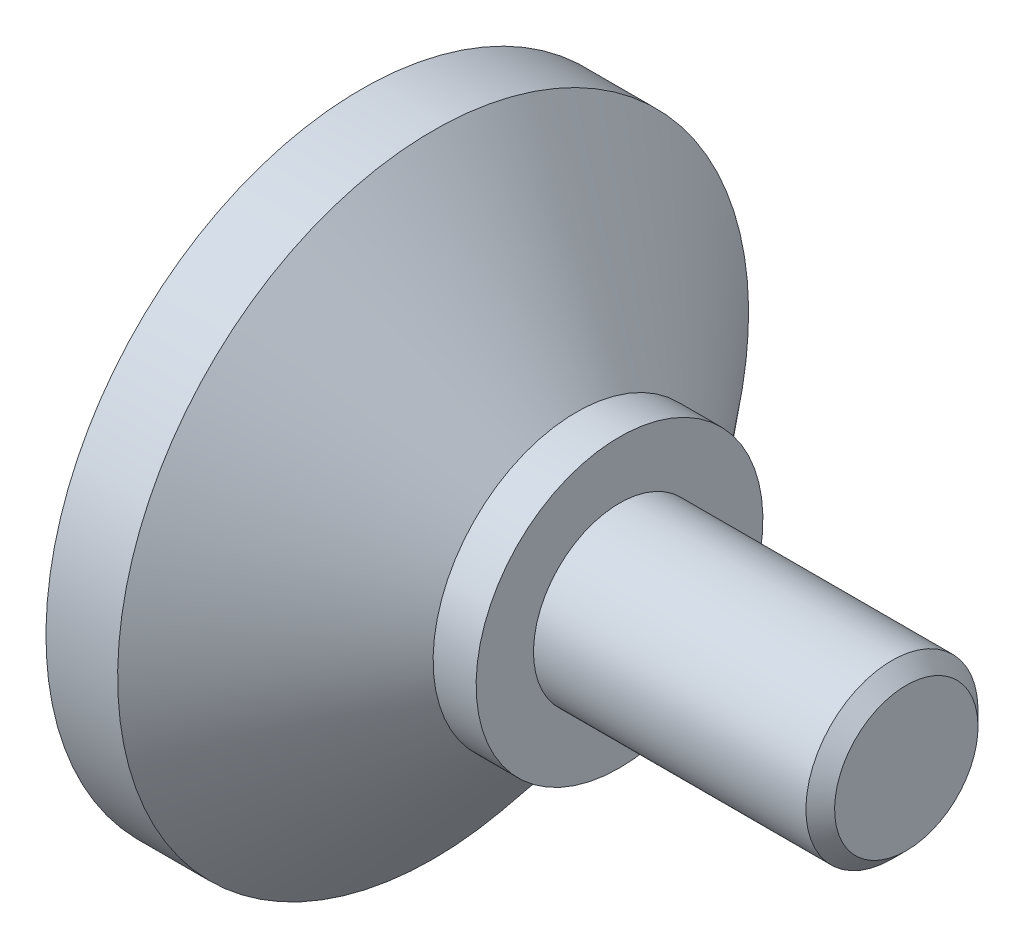
from build123d import *

# Parameters (mm, degrees)
CHAMFER1_SIZE = 0.5


with BuildPart() as part:
    # Sketch1 → Revolve1 (revolve)
    with BuildSketch(Plane.XY):
        Polygon((0, 0), (0, 3), (-10, 3), (-10, 5), (-11.5, 5), (-16.5, 11), (-19, 11), (-19, 0), align=None)
    revolve(axis=Axis((-19, 0, 0), (1, 0, 0)))

    # Chamfer1
    chamfer1_edges = [part.edges().sort_by_distance(p)[0] for p in [
        (0, -3, 0),
    ]]
    chamfer(chamfer1_edges, length=CHAMFER1_SIZE)


solid = part.part
